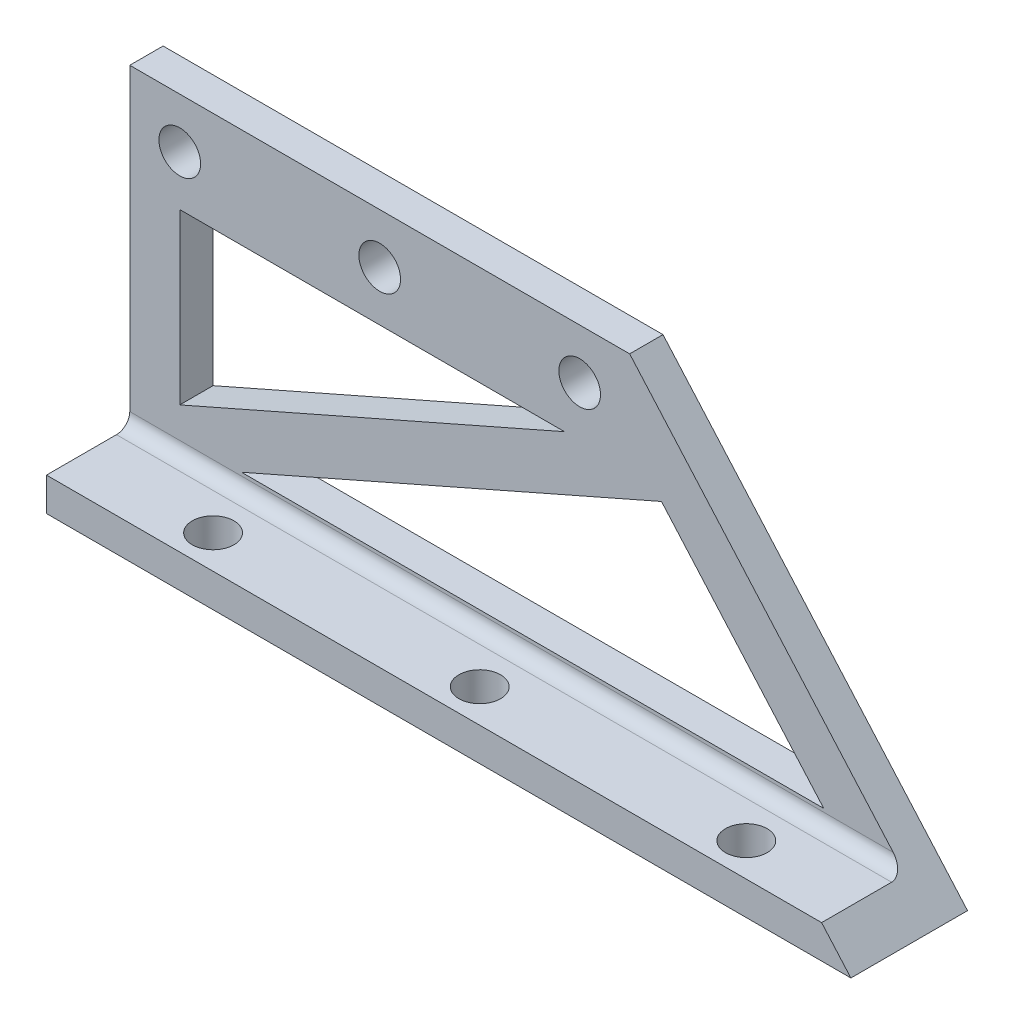
from build123d import *

# Parameters (mm, degrees)
SKETCH1_R           = 3.96875
BOSS_EXTRUDE1_DEPTH = 6.35
SKETCH2_W           = 153.277121284
SKETCH2_H           = 15.875
SKETCH2_R           = 3.96875
BOSS_EXTRUDE2_DEPTH = 6.35
FILLET1_R           = 2.54
CUT_EXTRUDE1_DEPTH  = 23.225


with BuildPart() as part:
    # Sketch1 → Boss-Extrude1 (new body)
    with BuildSketch(Plane.XY):
        Polygon((0, 0), (0, 66.04), (95.25, 66.04), (153.277121284, 0), align=None)
        with Locations((9.525, 56.515)):
            Circle(SKETCH1_R, mode=Mode.SUBTRACT)
        with Locations((47.625, 56.515)):
            Circle(SKETCH1_R, mode=Mode.SUBTRACT)
        with Locations((85.725, 56.515)):
            Circle(SKETCH1_R, mode=Mode.SUBTRACT)
        Polygon((9.525, 14.756535386), (9.525, 46.99), (82.829969346, 46.99), align=None, mode=Mode.SUBTRACT)
        Polygon((21.290817509, 9.525), (101.311219354, 44.71135659), (132.228284487, 9.525), align=None, mode=Mode.SUBTRACT)
    extrude(amount=BOSS_EXTRUDE1_DEPTH)

    # Sketch2 → Boss-Extrude2 (add)
    with BuildSketch(Plane.XZ):
        with Locations((76.638560642, 14.2875)):
            Rectangle(SKETCH2_W, SKETCH2_H)
        with Locations((25.4, 15.875)):
            Circle(SKETCH2_R, mode=Mode.SUBTRACT)
        with Locations((76.2, 15.875)):
            Circle(SKETCH2_R, mode=Mode.SUBTRACT)
        with Locations((127, 15.875)):
            Circle(SKETCH2_R, mode=Mode.SUBTRACT)
    extrude(amount=-BOSS_EXTRUDE2_DEPTH)

    # Fillet1
    fillet1_edges = [part.edges().sort_by_distance(p)[0] for p in [
        (73.848795196, 6.35, 6.35),
    ]]
    fillet(fillet1_edges, radius=FILLET1_R)

    # Sketch3 → Cut-Extrude1 (cut, through all)
    with BuildSketch(Plane(origin=(0, 0, 0), x_dir=(-1, 0, 0), z_dir=(0, 0, -1))):
        Polygon((-153.277121284, 0), (-143.877671223, 10.697406115), (-163.562021825, 13.552350256), (-165.283233358, 4.245452075), align=None)
    extrude(amount=-CUT_EXTRUDE1_DEPTH, mode=Mode.SUBTRACT)


solid = part.part
